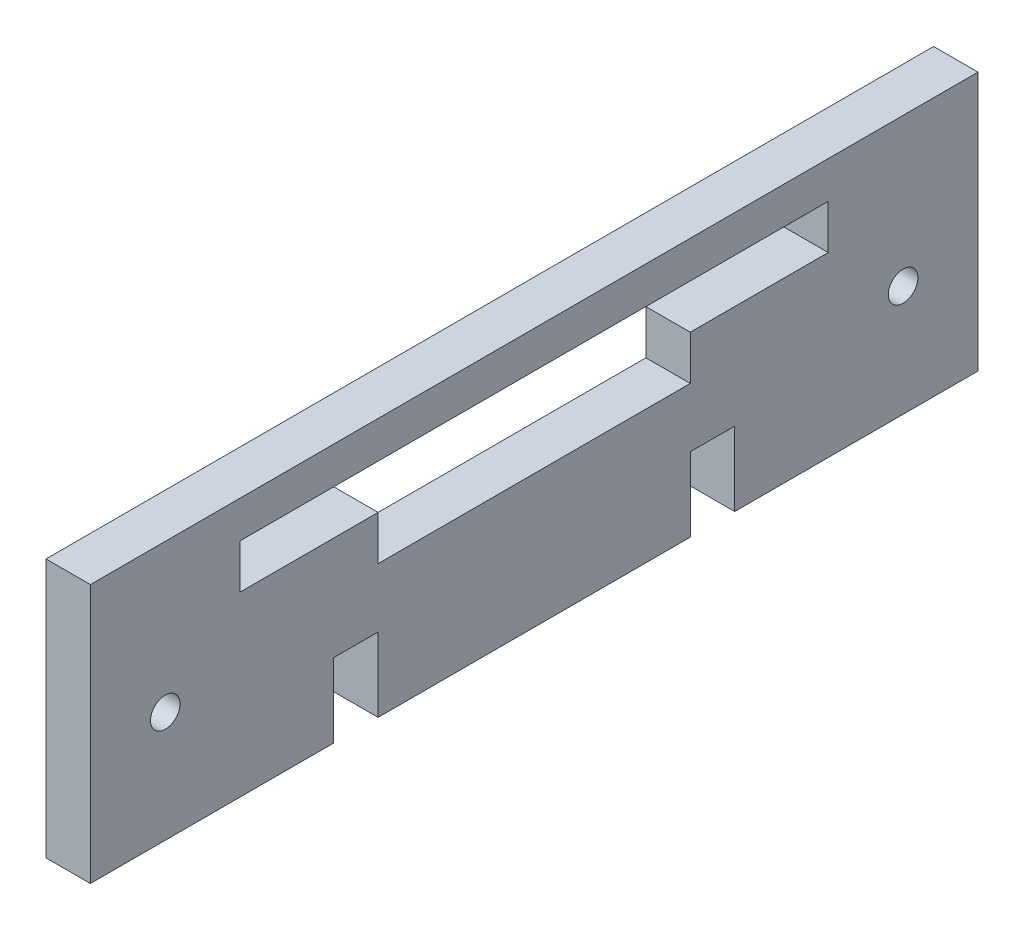
from build123d import *

# Parameters (mm, degrees)
BOSS_EXTRUDE1_DEPTH = 6
SKETCH2_R           = 2
CUT_EXTRUDE1_DEPTH  = 10
SKETCH3_W           = 6
SKETCH3_H           = 120
BOSS_EXTRUDE2_DEPTH = 5
SKETCH4_W           = 6
SKETCH4_H           = 10
CUT_EXTRUDE2_DEPTH  = 6
SKETCH5_W           = 42.2
SKETCH5_H           = 6
CUT_EXTRUDE3_DEPTH  = 7


with BuildPart() as part:
    # Sketch1 → Boss-Extrude1 (new body)
    with BuildSketch(Plane(origin=(0, 0, 0), x_dir=(0, 0, -1), z_dir=(1, 0, 0))):
        Polygon((39.75, 15), (39.75, 9), (-39.75, 9), (-39.75, 15), (-60, 15), (-60, -15), (60, -15), (60, 15), align=None)
    extrude(amount=BOSS_EXTRUDE1_DEPTH)

    # Sketch2 → Cut-Extrude1 (cut)
    with BuildSketch(Plane(origin=(6, 0, 0), x_dir=(0, 0, -1), z_dir=(1, 0, 0))):
        with Locations((-49.875, 0)):
            Circle(SKETCH2_R)
        with Locations((49.875, 0)):
            Circle(SKETCH2_R)
    extrude(amount=-CUT_EXTRUDE1_DEPTH, mode=Mode.SUBTRACT)

    # Sketch3 → Boss-Extrude2 (add)
    with BuildSketch(Plane(origin=(0, 15, 0), x_dir=(1, 0, 0), z_dir=(0, 1, 0))):
        with Locations((3, 0)):
            Rectangle(SKETCH3_W, SKETCH3_H)
    extrude(amount=BOSS_EXTRUDE2_DEPTH)

    # Sketch4 → Cut-Extrude2 (cut)
    with BuildSketch(Plane(origin=(6, 0, 0), x_dir=(0, 0, -1), z_dir=(1, 0, 0))):
        with Locations((-24.1, -10)):
            Rectangle(SKETCH4_W, SKETCH4_H)
        with Locations((24.1, -10)):
            Rectangle(SKETCH4_W, SKETCH4_H)
    extrude(amount=-CUT_EXTRUDE2_DEPTH, mode=Mode.SUBTRACT)

    # Sketch5 → Cut-Extrude3 (cut, through all)
    with BuildSketch(Plane(origin=(6, 0, 0), x_dir=(0, 0, -1), z_dir=(1, 0, 0))):
        with Locations((0, 6)):
            Rectangle(SKETCH5_W, SKETCH5_H)
    extrude(amount=-CUT_EXTRUDE3_DEPTH, mode=Mode.SUBTRACT)


solid = part.part
